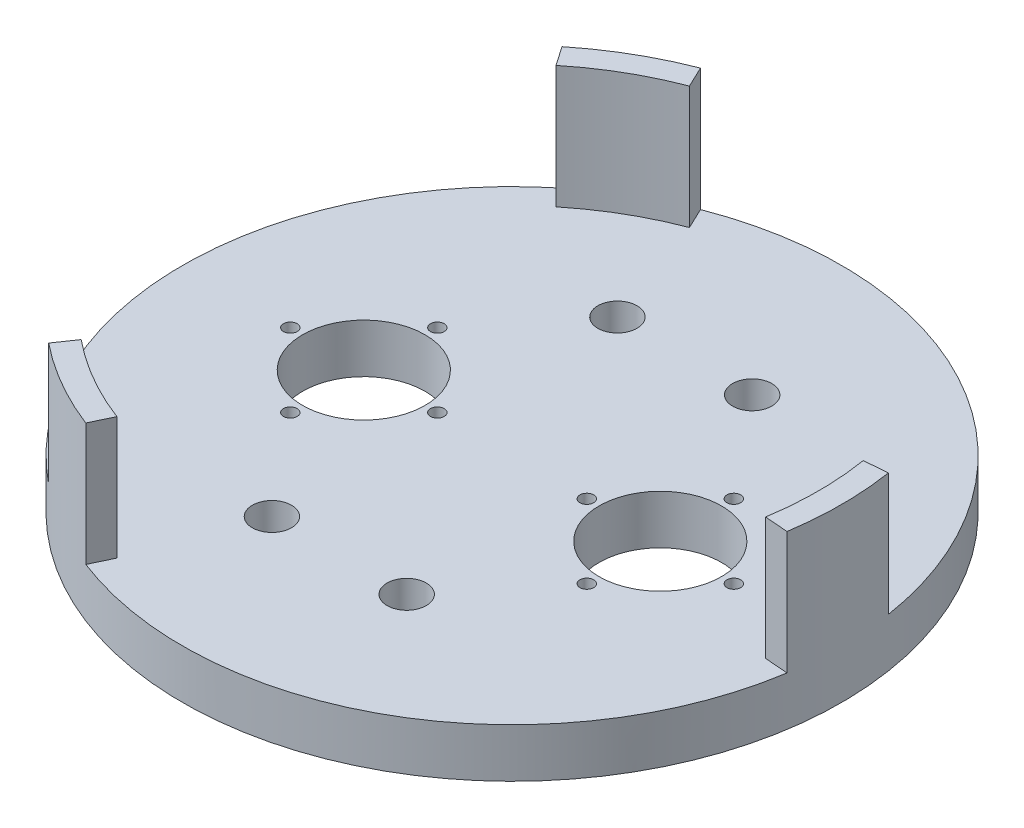
from build123d import *

# Parameters (mm, degrees)
SKETCH1_W           = 127.635
SKETCH1_H           = 127.635
MAIN_PLATE_DEPTH    = 12.7
SKETCH9_R           = 85.725
BOSS_EXTRUDE1_DEPTH = 12.7
SKETCH10_R          = 95.25
SKETCH10_R_2        = 85.4075
CUT_EXTRUDE1_DEPTH  = 167.64
SKETCH18_R          = 85.4075
SKETCH18_R_2        = 79.375
BOSS_EXTRUDE2_DEPTH = 38.1
SKETCH21_R          = 15.875
SKETCH21_R_2        = 1.778
CO2_MOUNTS_DEPTH    = 13.7
SKETCH22_R          = 5.08
CUT_EXTRUDE5_DEPTH  = 13.7
SKETCH23_R          = 79.375
CUT_EXTRUDE6_DEPTH  = 111.600000066


with BuildPart() as part:
    # Sketch1 → Main Plate (new body)
    with BuildSketch(Plane(origin=(0, 0, 0), x_dir=(1, 0, 0), z_dir=(0, 1, 0))):
        with Locations((63.8175, 63.8175)):
            Rectangle(SKETCH1_W, SKETCH1_H)
    extrude(amount=MAIN_PLATE_DEPTH)

    # Sketch9 → Boss-Extrude1 (add)
    with BuildSketch(Plane(origin=(0, 12.7, 0), x_dir=(1, 0, 0), z_dir=(0, 1, 0))):
        with Locations((63.8175, 63.8175)):
            Circle(SKETCH9_R)
    extrude(amount=-BOSS_EXTRUDE1_DEPTH)

    # Sketch10 → Cut-Extrude1 (cut)
    with BuildSketch(Plane(origin=(0, 12.7, 0), x_dir=(1, 0, 0), z_dir=(0, 1, 0))):
        with Locations((63.8175, 63.8175)):
            Circle(SKETCH10_R)
        with Locations((63.8175, 63.8175)):
            Circle(SKETCH10_R_2, mode=Mode.SUBTRACT)
    extrude(amount=-CUT_EXTRUDE1_DEPTH, mode=Mode.SUBTRACT)

    # Sketch18 → Boss-Extrude2 (add)
    with BuildSketch(Plane(origin=(0, 6.35, 0), x_dir=(1, 0, 0), z_dir=(0, 1, 0))):
        with Locations((63.8175, 63.8175)):
            Circle(SKETCH18_R)
        with Locations((63.8175, 63.8175)):
            Circle(SKETCH18_R_2, mode=Mode.SUBTRACT)
    extrude(amount=BOSS_EXTRUDE2_DEPTH)

    # Sketch21 → CO2 Mounts (cut, through all)
    with BuildSketch(Plane(origin=(0, 12.7, 0), x_dir=(1, 0, 0), z_dir=(0, 1, 0))):
        with Locations((102.235, 63.8175)):
            Circle(SKETCH21_R)
        with Locations((102.235, 82.8675)):
            Circle(SKETCH21_R_2)
        with Locations((25.4, 63.8175)):
            Circle(SKETCH21_R)
        with Locations((121.285, 63.8175)):
            Circle(SKETCH21_R_2)
        with Locations((102.235, 44.7675)):
            Circle(SKETCH21_R_2)
        with Locations((83.185, 63.8175)):
            Circle(SKETCH21_R_2)
        with Locations((25.4, 82.8675)):
            Circle(SKETCH21_R_2)
        with Locations((6.35, 63.8175)):
            Circle(SKETCH21_R_2)
        with Locations((25.4, 44.7675)):
            Circle(SKETCH21_R_2)
        with Locations((44.45, 63.8175)):
            Circle(SKETCH21_R_2)
    extrude(amount=-CO2_MOUNTS_DEPTH, mode=Mode.SUBTRACT)

    # Sketch22 → Cut-Extrude5 (cut, through all)
    with BuildSketch(Plane(origin=(0, 12.7, 0), x_dir=(1, 0, 0), z_dir=(0, 1, 0))):
        with Locations((46.355, 108.585)):
            Circle(SKETCH22_R)
        with Locations((81.28, 108.585)):
            Circle(SKETCH22_R)
        with Locations((81.28, 19.05)):
            Circle(SKETCH22_R)
        with Locations((46.355, 19.05)):
            Circle(SKETCH22_R)
    extrude(amount=-CUT_EXTRUDE5_DEPTH, mode=Mode.SUBTRACT)

    # Sketch23 → Cut-Extrude6 (cut)
    with BuildSketch(Plane(origin=(0, 12.7, 0), x_dir=(1, 0, 0), z_dir=(0, 1, 0))):
        with Locations((63.8175, 63.8175)):
            Circle(SKETCH23_R)
        with BuildLine():
            Line((13.678739997, 125.352005526), (7.552270878, 134.237860218))
            Line((7.552270878, 134.237860218), (-19.267108419, 125.320629884))
            Line((-19.267108419, 125.320629884), (-48.79695837, 60.397770071))
            Line((-48.79695837, 60.397770071), (-9.884344094, 7.052469015))
            Line((-9.884344094, 7.052469015), (6.959175986, -7.46308736))
            Line((6.959175986, -7.46308736), (13.678739997, 2.282994474))
            ThreePointArc((13.678739997, 2.282994474), (-15.5575, 63.8175), (13.678739997, 125.352005526))
        make_face()
        with BuildLine():
            Line((142.177324996, 76.471687114), (152.935935453, 77.334437661))
            Line((152.935935453, 77.334437661), (158.623077101, 105.019316613))
            Line((158.623077101, 105.019316613), (117.163156193, 163.054346747))
            Line((117.163156193, 163.054346747), (51.508463168, 156.027684783))
            Line((51.508463168, 156.027684783), (30.515862556, 148.698546693))
            Line((30.515862556, 148.698546693), (35.596435007, 138.00619264))
            ThreePointArc((35.596435007, 138.00619264), (103.505, 132.558266425), (142.177324996, 76.471687114))
        make_face()
        with BuildLine():
            Line((35.596435007, -10.37119264), (30.964293669, -20.119797879))
            Line((30.964293669, -20.119797879), (52.096531318, -38.887446496))
            Line((52.096531318, -38.887446496), (123.086302178, -31.999616818))
            Line((123.086302178, -31.999616818), (149.828380926, 28.372346201))
            Line((149.828380926, 28.372346201), (153.977461458, 50.217040667))
            Line((153.977461458, 50.217040667), (142.177324996, 51.163312886))
            ThreePointArc((142.177324996, 51.163312886), (103.505, -4.923266425), (35.596435007, -10.37119264))
        make_face()
    extrude(amount=CUT_EXTRUDE6_DEPTH, mode=Mode.SUBTRACT)


solid = part.part
